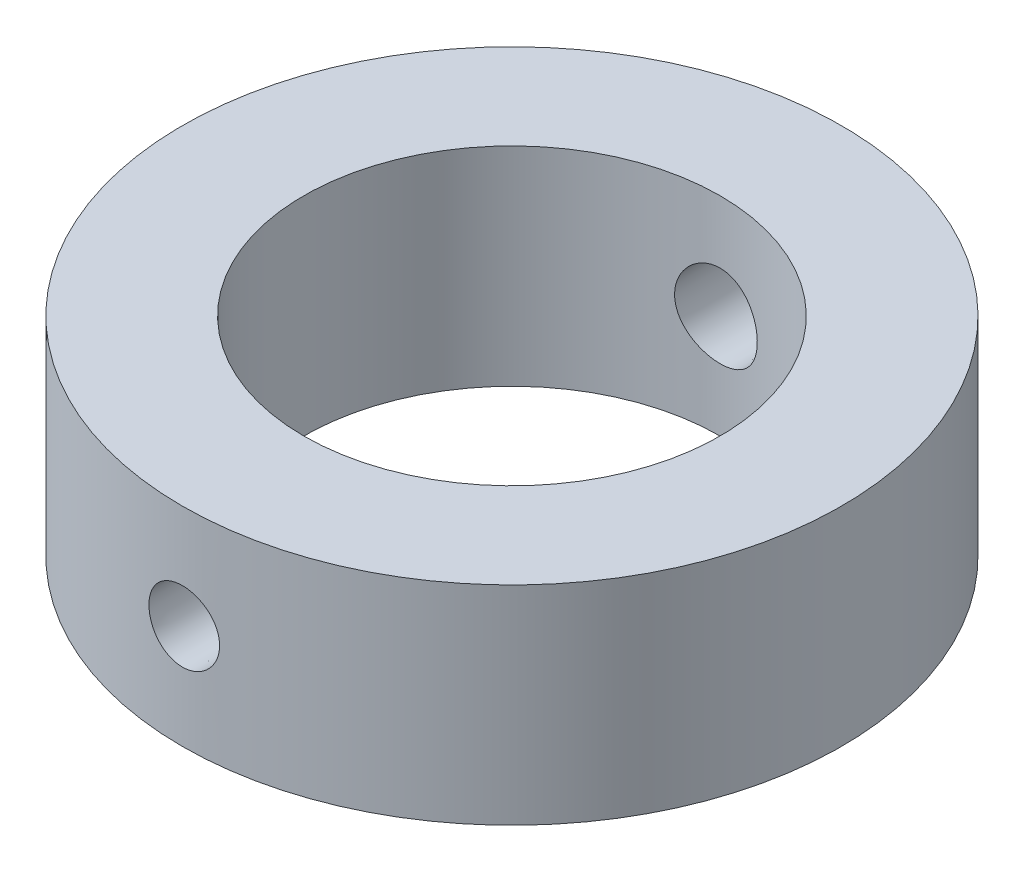
from build123d import *

# Parameters (mm, degrees)
SKETCH1_R           = 19
SKETCH1_R_2         = 12
BOSS_EXTRUDE1_DEPTH = 6


with BuildPart() as part:
    # Sketch1 → Boss-Extrude1 (new body, symmetric)
    with BuildSketch(Plane(origin=(0, 0, 0), x_dir=(1, 0, 0), z_dir=(0, 1, 0))):
        Circle(SKETCH1_R)
        Circle(SKETCH1_R_2, mode=Mode.SUBTRACT)
    extrude(amount=BOSS_EXTRUDE1_DEPTH, both=True)

    # Sketch2 → Cut-Revolve1 (revolve, cut)
    with BuildSketch(Plane(origin=(0, 0, 0), x_dir=(1, 0, 0), z_dir=(0, 1, 0))):
        Polygon((0, 22), (0, -22), (2, -22), (2.5, 22), align=None)
    revolve(axis=Axis((0, 0, -26.003072041), (0, 0, 1)), mode=Mode.SUBTRACT)


solid = part.part
